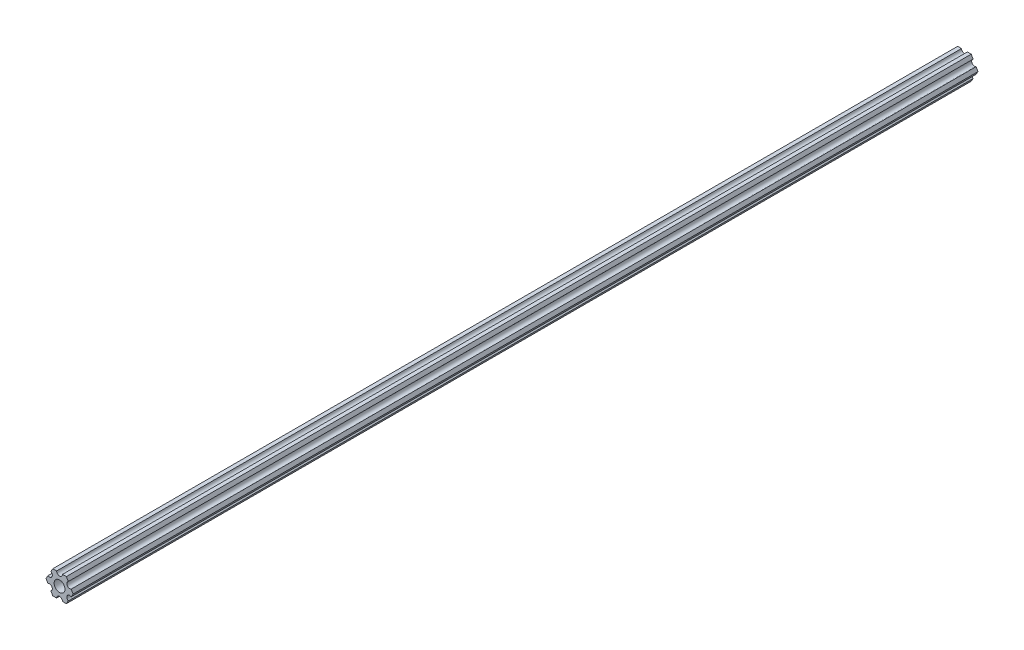
from build123d import *

# Parameters (mm, degrees)
SKETCH1_R           = 2.9337
BOSS_EXTRUDE1_DEPTH = 488.95


with BuildPart() as part:
    # Sketch1 → Boss-Extrude1 (new body)
    with BuildSketch(Plane.XY):
        with BuildLine():
            Line((-1.587500385, 6.349999904), (-3.666174594, 6.349999778))
            Line((-3.666174594, 6.349999778), (-4.70551159, 4.549815043))
            ThreePointArc((-4.70551159, 4.549815043), (-4.12444613, 2.38124975), (-6.293011423, 1.80018429))
            Line((-6.293011423, 1.80018429), (-7.332348419, -4.44e-07))
            Line((-7.332348419, -4.44e-07), (-6.293011205, -1.800185053))
            ThreePointArc((-6.293011205, -1.800185053), (-4.124445841, -2.38125025), (-4.705511038, -4.549815614))
            Line((-4.705511038, -4.549815614), (-3.666173825, -6.350000222))
            Line((-3.666173825, -6.350000222), (-1.587499615, -6.350000096))
            ThreePointArc((-1.587499615, -6.350000096), (2.89e-07, -4.7625), (1.587500385, -6.349999904))
            Line((1.587500385, -6.349999904), (3.666174594, -6.349999778))
            Line((3.666174594, -6.349999778), (4.70551159, -4.549815043))
            ThreePointArc((4.70551159, -4.549815043), (4.12444613, -2.38124975), (6.293011423, -1.80018429))
            Line((6.293011423, -1.80018429), (7.332348419, 4.44e-07))
            Line((7.332348419, 4.44e-07), (6.293011205, 1.800185053))
            ThreePointArc((6.293011205, 1.800185053), (4.124445841, 2.38125025), (4.705511038, 4.549815614))
            Line((4.705511038, 4.549815614), (3.666173825, 6.350000222))
            Line((3.666173825, 6.350000222), (1.587499615, 6.350000096))
            ThreePointArc((1.587499615, 6.350000096), (-2.89e-07, 4.7625), (-1.587500385, 6.349999904))
        make_face()
        Circle(SKETCH1_R, mode=Mode.SUBTRACT)
    extrude(amount=BOSS_EXTRUDE1_DEPTH)


solid = part.part
